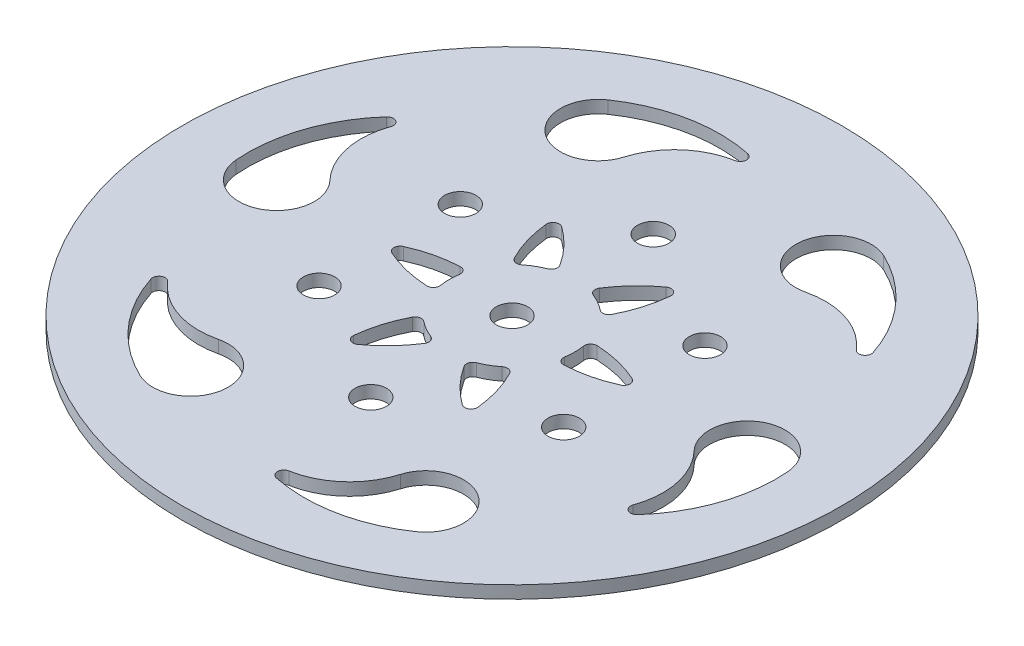
from build123d import *

# Parameters (mm, degrees)
SKETCH_1_R          = 52.5
SKETCH_1_R_2        = 2.5
EXTRUDE_1_DEPTH     = 2
SKETCH_2_R          = 2.5
CUT_EXTRUDE_1_DEPTH = 3
CUT_EXTRUDE_2_DEPTH = 3
FILLET_1_R          = 1


with BuildPart() as part:
    # 草图1 → 凸台-拉伸1 (new body)
    with BuildSketch(Plane(origin=(0, 0, 0), x_dir=(1, 0, 0), z_dir=(0, 1, 0))):
        Circle(SKETCH_1_R)
        Circle(SKETCH_1_R_2, mode=Mode.SUBTRACT)
    extrude(amount=EXTRUDE_1_DEPTH)

    # 草图2 → 切除-拉伸1 (cut, through all)
    with BuildSketch(Plane(origin=(0, 2, 0), x_dir=(1, 0, 0), z_dir=(0, 1, 0))):
        with Locations((0, 22.5)):
            Circle(SKETCH_2_R)
        with Locations((19.485571585, 11.25)):
            Circle(SKETCH_2_R)
        with Locations((19.485571585, -11.25)):
            Circle(SKETCH_2_R)
        with Locations((0, -22.5)):
            Circle(SKETCH_2_R)
        with Locations((-19.485571585, -11.25)):
            Circle(SKETCH_2_R)
        with Locations((-19.485571585, 11.25)):
            Circle(SKETCH_2_R)
    extrude(amount=-CUT_EXTRUDE_1_DEPTH, mode=Mode.SUBTRACT)

    # 草图3 → 切除-拉伸2 (cut, through all)
    with BuildSketch(Plane(origin=(0, 2, 0), x_dir=(1, 0, 0), z_dir=(0, 1, 0))):
        with BuildLine():
            ThreePointArc((-22.155602008, 37.41577804), (-22.27211138, 27.618511811), (-12.996323739, 30.774421131))
            ThreePointArc((-12.996323739, 30.774421131), (-9.500367402, 36.305423878), (-3.622483775, 39.180173636))
            ThreePointArc((-3.622483775, 39.180173636), (-2.800378137, 40.149983716), (-3.594497467, 41.142840081))
            ThreePointArc((-3.594497467, 41.142840081), (-13.258070622, 41.186787552), (-22.155602008, 37.41577804))
        make_face()
        with BuildLine():
            ThreePointArc((21.325213281, 37.895203195), (12.782277153, 33.097470157), (20.153268617, 26.642357079))
            ThreePointArc((20.153268617, 26.642357079), (26.691235672, 26.380271454), (32.119783806, 22.727249792))
            ThreePointArc((32.119783806, 22.727249792), (33.370716791, 22.500190465), (33.833495961, 23.684346161))
            ThreePointArc((33.833495961, 23.684346161), (29.039769009, 32.075219739), (21.325213281, 37.895203195))
        make_face()
        with BuildLine():
            ThreePointArc((43.480815289, 0.479425154), (35.054388533, 5.478958346), (33.149592355, -4.132064052))
            ThreePointArc((33.149592355, -4.132064052), (36.191603074, -9.925152424), (35.742267581, -16.452923844))
            ThreePointArc((35.742267581, -16.452923844), (36.171094928, -17.649793251), (37.427993428, -17.45849392))
            ThreePointArc((37.427993428, -17.45849392), (42.297839631, -9.111567812), (43.480815289, 0.479425154))
        make_face()
        with BuildLine():
            ThreePointArc((22.155602008, -37.41577804), (22.27211138, -27.618511811), (12.996323739, -30.774421131))
            ThreePointArc((12.996323739, -30.774421131), (9.500367402, -36.305423878), (3.622483775, -39.180173636))
            ThreePointArc((3.622483775, -39.180173636), (2.800378137, -40.149983716), (3.594497467, -41.142840081))
            ThreePointArc((3.594497467, -41.142840081), (13.258070622, -41.186787552), (22.155602008, -37.41577804))
        make_face()
        with BuildLine():
            ThreePointArc((-21.325213281, -37.895203195), (-12.782277153, -33.097470157), (-20.153268617, -26.642357079))
            ThreePointArc((-20.153268617, -26.642357079), (-26.691235672, -26.380271454), (-32.119783806, -22.727249792))
            ThreePointArc((-32.119783806, -22.727249792), (-33.370716791, -22.500190465), (-33.833495961, -23.684346161))
            ThreePointArc((-33.833495961, -23.684346161), (-29.039769009, -32.075219739), (-21.325213281, -37.895203195))
        make_face()
        with BuildLine():
            ThreePointArc((-43.480815289, -0.479425154), (-35.054388533, -5.478958346), (-33.149592355, 4.132064052))
            ThreePointArc((-33.149592355, 4.132064052), (-36.191603074, 9.925152424), (-35.742267581, 16.452923844))
            ThreePointArc((-35.742267581, 16.452923844), (-36.171094928, 17.649793251), (-37.427993428, 17.45849392))
            ThreePointArc((-37.427993428, 17.45849392), (-42.297839631, 9.111567812), (-43.480815289, -0.479425154))
        make_face()
        with BuildLine():
            ThreePointArc((-2.5, 9.682458366), (-5, 8.660254038), (-7.135254916, 7.006292692))
            ThreePointArc((-7.135254916, 7.006292692), (-9.270509831, 11.968176729), (-10, 17.320508076))
            ThreePointArc((-10, 17.320508076), (-5.729490169, 14.012585384), (-2.5, 9.682458366))
        make_face()
        with BuildLine():
            ThreePointArc((2.5, 9.682458366), (5.729490169, 14.012585384), (10, 17.320508076))
            ThreePointArc((10, 17.320508076), (9.270509831, 11.968176729), (7.135254916, 7.006292692))
            ThreePointArc((7.135254916, 7.006292692), (5, 8.660254038), (2.5, 9.682458366))
        make_face()
        with BuildLine():
            ThreePointArc((9.635254916, 2.676165673), (15, 2.044408655), (20, 0))
            ThreePointArc((20, 0), (15, -2.044408655), (9.635254916, -2.676165673))
            ThreePointArc((9.635254916, -2.676165673), (10, 0), (9.635254916, 2.676165673))
        make_face()
        with BuildLine():
            ThreePointArc((7.135254916, -7.006292692), (9.270509831, -11.968176729), (10, -17.320508076))
            ThreePointArc((10, -17.320508076), (5.729490169, -14.012585384), (2.5, -9.682458366))
            ThreePointArc((2.5, -9.682458366), (5, -8.660254038), (7.135254916, -7.006292692))
        make_face()
        with BuildLine():
            ThreePointArc((-2.5, -9.682458366), (-5.729490169, -14.012585384), (-10, -17.320508076))
            ThreePointArc((-10, -17.320508076), (-9.270509831, -11.968176729), (-7.135254916, -7.006292692))
            ThreePointArc((-7.135254916, -7.006292692), (-5, -8.660254038), (-2.5, -9.682458366))
        make_face()
        with BuildLine():
            ThreePointArc((-9.635254916, -2.676165673), (-15, -2.044408655), (-20, 0))
            ThreePointArc((-20, 0), (-15, 2.044408655), (-9.635254916, 2.676165673))
            ThreePointArc((-9.635254916, 2.676165673), (-10, 0), (-9.635254916, -2.676165673))
        make_face()
    extrude(amount=-CUT_EXTRUDE_2_DEPTH, mode=Mode.SUBTRACT)

    # 圆角1
    fillet_1_edges = [part.edges().sort_by_distance(p)[0] for p in [
        (9.635254916, 1, 2.676165673),
        (9.635254916, 1, -2.676165673),
        (20, 1, 0),
        (-7.135254916, 1, -7.006292692),
        (-10, 1, -17.320508076),
        (-2.5, 1, -9.682458366),
        (7.135254916, 1, -7.006292692),
        (2.5, 1, -9.682458366),
        (10, 1, -17.320508076),
        (2.5, 1, 9.682458366),
        (7.135254916, 1, 7.006292692),
        (10, 1, 17.320508076),
        (-7.135254916, 1, 7.006292692),
        (-2.5, 1, 9.682458366),
        (-10, 1, 17.320508076),
        (-9.635254916, 1, -2.676165673),
        (-9.635254916, 1, 2.676165673),
        (-20, 1, 0),
    ]]
    fillet(fillet_1_edges, radius=FILLET_1_R)


solid = part.part
